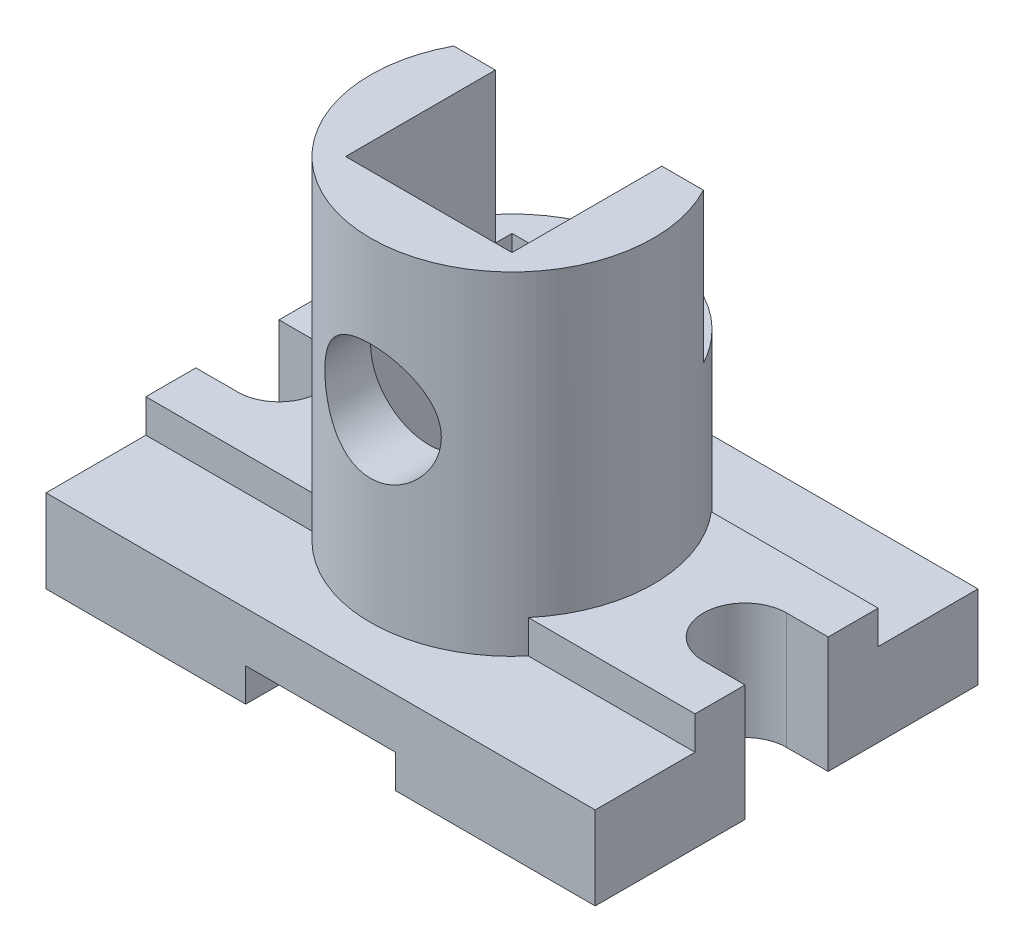
from build123d import *

# Parameters (mm, degrees)
SKETCH_1_W          = 66
SKETCH_1_H          = 46
EXTRUDE_1_DEPTH     = 10
SKETCH_2_W          = 66
SKETCH_2_H          = 22
EXTRUDE_2_DEPTH     = 4
SKETCH_3_R          = 17
EXTRUDE_3_DEPTH     = 50
SKETCH_4_W          = 18
SKETCH_4_H          = 4
CUT_EXTRUDE_1_DEPTH = 47
CUT_EXTRUDE_2_DEPTH = 15
SKETCH_6_W          = 20
SKETCH_6_H          = 20
CUT_EXTRUDE_3_DEPTH = 51
CUT_EXTRUDE_4_DEPTH = 18
SKETCH_8_R          = 7
CUT_EXTRUDE_5_DEPTH = 24
SKETCH_9_R          = 19
CUT_EXTRUDE_6_DEPTH = 6


with BuildPart() as part:
    # 草图1 → 凸台-拉伸1 (new body)
    with BuildSketch(Plane(origin=(0, 0, 0), x_dir=(1, 0, 0), z_dir=(0, 1, 0))):
        Rectangle(SKETCH_1_W, SKETCH_1_H)
    extrude(amount=EXTRUDE_1_DEPTH)

    # 草图2 → 凸台-拉伸2 (add)
    with BuildSketch(Plane(origin=(0, 10, 0), x_dir=(1, 0, 0), z_dir=(0, 1, 0))):
        Rectangle(SKETCH_2_W, SKETCH_2_H)
    extrude(amount=EXTRUDE_2_DEPTH)

    # 草图3 → 凸台-拉伸3 (add)
    with BuildSketch(Plane(origin=(0, 0, 0), x_dir=(1, 0, 0), z_dir=(0, 1, 0))):
        Circle(SKETCH_3_R)
    extrude(amount=EXTRUDE_3_DEPTH)

    # 草图4 → 切除-拉伸1 (cut, through all)
    with BuildSketch(Plane.XY.offset(23)):
        with Locations((0, 2)):
            Rectangle(SKETCH_4_W, SKETCH_4_H)
    extrude(amount=-CUT_EXTRUDE_1_DEPTH, mode=Mode.SUBTRACT)

    # 草图5 → 切除-拉伸2 (cut, through all)
    with BuildSketch(Plane(origin=(0, 14, 0), x_dir=(1, 0, 0), z_dir=(0, 1, 0))):
        with BuildLine():
            Line((-28, 5), (-33, 5))
            Line((-33, 5), (-33, -5))
            Line((-33, -5), (-28.383132006, -4.985299376))
            ThreePointArc((-28.383132006, -4.985299376), (-23.003676508, -0.191706965), (-28, 5))
        make_face()
        with BuildLine():
            Line((33, -5), (28.383132006, -4.985299376))
            ThreePointArc((28.383132006, -4.985299376), (23.003676508, -0.191706965), (28, 5))
            Line((28, 5), (33, 5))
            Line((33, 5), (33, -5))
        make_face()
    extrude(amount=-CUT_EXTRUDE_2_DEPTH, mode=Mode.SUBTRACT)

    # 草图6 → 切除-拉伸3 (cut, through all)
    with BuildSketch(Plane(origin=(0, 50, 0), x_dir=(1, 0, 0), z_dir=(0, 1, 0))):
        Rectangle(SKETCH_6_W, SKETCH_6_H)
    extrude(amount=-CUT_EXTRUDE_3_DEPTH, mode=Mode.SUBTRACT)

    # 草图7 → 切除-拉伸4 (cut)
    with BuildSketch(Plane(origin=(0, 50, 0), x_dir=(1, 0, 0), z_dir=(0, 1, 0))):
        with BuildLine():
            Line((-15, 8), (-10, 8))
            Line((-10, 8), (-10, 10))
            Line((-10, 10), (10, 10))
            Line((10, 10), (10, 8))
            Line((10, 8), (15, 8))
            ThreePointArc((15, 8), (0, 17), (-15, 8))
        make_face()
    extrude(amount=-CUT_EXTRUDE_4_DEPTH, mode=Mode.SUBTRACT)

    # 草图8 → 切除-拉伸5 (cut, through all)
    with BuildSketch(Plane.XY):
        with Locations((0, 32)):
            Circle(SKETCH_8_R)
    extrude(amount=CUT_EXTRUDE_5_DEPTH, mode=Mode.SUBTRACT)

    # 草图9 → 切除-拉伸6 (cut)
    with BuildSketch(Plane(origin=(0, 0, 0), x_dir=(1, 0, 0), z_dir=(0, 1, 0))):
        Circle(SKETCH_9_R)
    extrude(amount=CUT_EXTRUDE_6_DEPTH, mode=Mode.SUBTRACT)


solid = part.part
